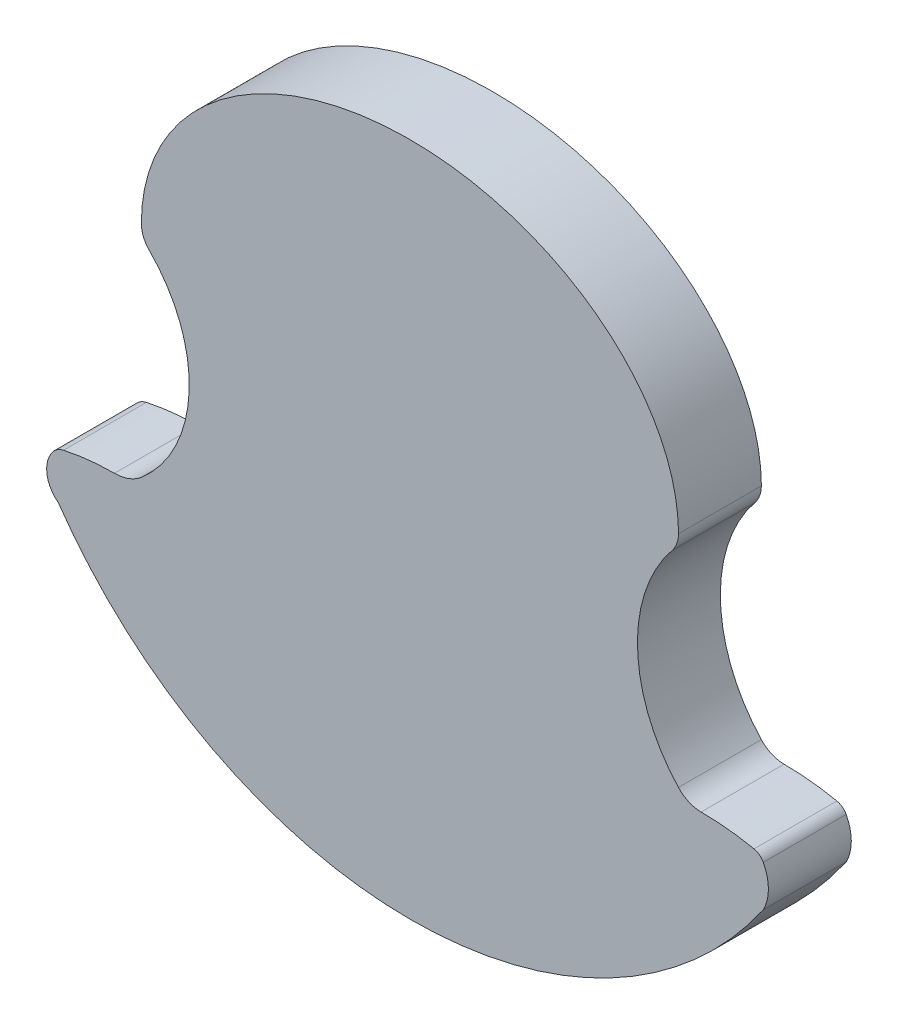
from build123d import *

# Parameters (mm, degrees)
BOSS_EXTRU_1_DEPTH = 20


with BuildPart() as part:
    # Esquisse6 → Boss.-Extru.1 (new body)
    with BuildSketch(Plane.XY):
        with BuildLine():
            Line((4.5, 61.567165471), (4.5, 164.30674647))
            ThreePointArc((4.5, 164.30674647), (-1.55264084, 164.295759109), (-7.604944348, 164.36059811))
            Line((-7.604944348, 164.36059811), (-7.604944348, 61.775961488))
            ThreePointArc((-7.604944348, 61.775961488), (-1.555531667, 61.494189457), (4.5, 61.567165471))
        make_face()
        with BuildLine():
            ThreePointArc((59.481608112, 167.89289536), (32.041968039, 165.315392232), (4.5, 164.30674647))
            Line((4.5, 164.30674647), (4.5, 61.567165471))
            ThreePointArc((4.5, 61.567165471), (50.123542145, 74.319050976), (85.267388278, 106.084256166))
            ThreePointArc((85.267388278, 106.084256166), (86.500680528, 111.034962965), (85.267388279, 115.985669764))
            ThreePointArc((85.267388279, 115.985669764), (84.330611254, 117.081825908), (83.017507863, 117.677534709))
            ThreePointArc((83.017507863, 117.677534709), (76.676755995, 118.670057439), (70.267388279, 119.002083189))
            ThreePointArc((70.267388279, 119.002083189), (68.070131486, 119.333237998), (66.068077904, 120.297282796))
            ThreePointArc((66.068077904, 120.297282796), (37.807250866, 126.623946295), (8.972937884, 129.322725787))
            Line((8.972937884, 129.322725787), (8.972937884, 154.353958189))
            ThreePointArc((8.972937884, 154.353958189), (33.751131209, 157.773663164), (58.351622593, 162.297938822))
            ThreePointArc((58.351622593, 162.297938822), (60.575585043, 166.403653342), (63.29612356, 170.19859351))
            ThreePointArc((63.29612356, 170.19859351), (61.588166604, 168.716023972), (59.481608112, 167.89289536))
        make_face()
        with BuildLine():
            ThreePointArc((64.7925, 121.397120586), (55.359525997, 140.86920751), (58.351622593, 162.297938822))
            ThreePointArc((58.351622593, 162.297938822), (33.751131209, 157.773663164), (8.972937884, 154.353958189))
            Line((8.972937884, 154.353958189), (8.972937884, 129.322725787))
            ThreePointArc((8.972937884, 129.322725787), (37.807250866, 126.623946295), (66.068077904, 120.297282796))
            ThreePointArc((66.068077904, 120.297282796), (65.399129792, 120.811063694), (64.7925, 121.397120586))
        make_face()
        with BuildLine():
            Line((-7.604944348, 61.775961488), (-7.604944348, 164.36059811))
            ThreePointArc((-7.604944348, 164.36059811), (-32.993073747, 165.460053215), (-58.288274775, 167.89289536))
            ThreePointArc((-58.288274775, 167.89289536), (-60.777334009, 168.388000025), (-62.887456538, 169.797938822))
            ThreePointArc((-62.887456538, 169.797938822), (-59.81103303, 166.248463709), (-57.270067013, 162.297938822))
            ThreePointArc((-57.270067013, 162.297938822), (-34.681953624, 157.774784594), (-11.905538615, 154.322725787))
            Line((-11.905538615, 154.322725787), (-11.905538615, 129.322725787))
            ThreePointArc((-11.905538615, 129.322725787), (-39.342848652, 126.996825713), (-66.09079192, 120.457458456))
            ThreePointArc((-66.09079192, 120.457458456), (-68.588354522, 119.372798497), (-71.285923119, 119.002083189))
            ThreePointArc((-71.285923119, 119.002083189), (-77.462771892, 118.669988882), (-83.568407168, 117.677534709))
            ThreePointArc((-83.568407168, 117.677534709), (-85.039797053, 117.06846799), (-86.207486425, 115.985669764))
            ThreePointArc((-86.207486425, 115.985669764), (-87.56092068, 110.746166789), (-84.813055137, 106.084256166))
            ThreePointArc((-84.813055137, 106.084256166), (-51.223040292, 75.193040496), (-7.604944348, 61.775961488))
        make_face()
        with BuildLine():
            ThreePointArc((-11.905538615, 154.322725787), (-34.681953624, 157.774784594), (-57.270067013, 162.297938822))
            ThreePointArc((-57.270067013, 162.297938822), (-53.772005443, 140.512411359), (-64.7925, 121.397120586))
            ThreePointArc((-64.7925, 121.397120586), (-65.422791128, 120.901238587), (-66.09079192, 120.457458456))
            ThreePointArc((-66.09079192, 120.457458456), (-39.342848652, 126.996825713), (-11.905538615, 129.322725787))
            Line((-11.905538615, 129.322725787), (-11.905538615, 154.322725787))
        make_face()
        with BuildLine():
            add(Edge.make_bspline(
                [(64.7925, 174.397120586), (64.7925, 224.397120586), (0, 224.397120586)],
                knots=[0, 0, 0, 1.570796327, 1.570796327, 1.570796327], degree=2, weights=[1, 0.707106781, 1]))
            add(Edge.make_bspline(
                [(0, 224.397120586), (-64.7925, 224.397120586), (-64.7925, 174.397120586)],
                knots=[1.570796327, 1.570796327, 1.570796327, 3.141592654, 3.141592654, 3.141592654], degree=2, weights=[1, 0.707106781, 1]))
            ThreePointArc((-64.7925, 174.397120586), (-62.887456538, 169.797938822), (-58.288274775, 167.89289536))
            ThreePointArc((-58.288274775, 167.89289536), (0.596666669, 164.290978287), (59.481608112, 167.89289536))
            ThreePointArc((59.481608112, 167.89289536), (63.29612356, 170.19859351), (64.7925, 174.397120586))
        make_face()
    extrude(amount=BOSS_EXTRU_1_DEPTH)


solid = part.part
